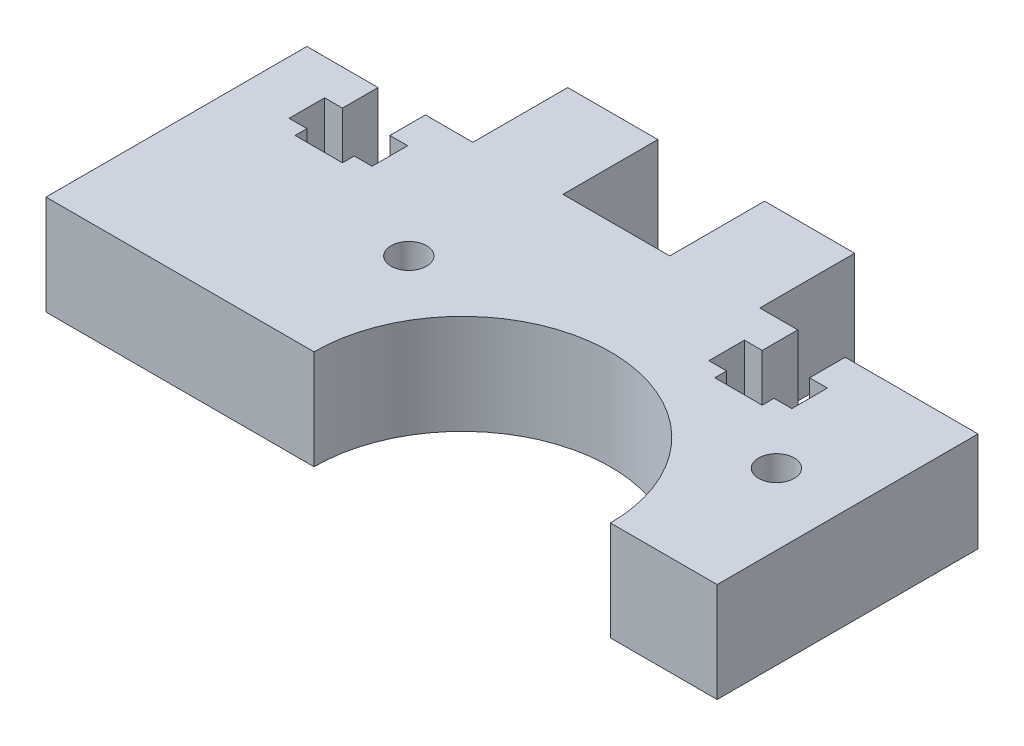
from build123d import *

# Parameters (mm, degrees)
SKETCH1_R           = 1.5
BOSS_EXTRUDE1_DEPTH = 8.4


with BuildPart() as part:
    # Sketch1 → Boss-Extrude1 (new body)
    with BuildSketch(Plane(origin=(0, 0, 0), x_dir=(1, 0, 0), z_dir=(0, 1, 0))):
        with BuildLine():
            Line((-28.3, 11), (-22.3, 11))
            Line((-22.3, 11), (-22.3, 8))
            Line((-22.3, 8), (-23.8, 8))
            Line((-23.8, 8), (-23.8, 5))
            Line((-23.8, 5), (-22.3, 5))
            Line((-22.3, 5), (-22.3, 4))
            Line((-22.3, 4), (-18.3, 4))
            Line((-18.3, 4), (-18.3, 5))
            Line((-18.3, 5), (-16.8, 5))
            Line((-16.8, 5), (-16.8, 8))
            Line((-16.8, 8), (-18.3, 8))
            Line((-18.3, 8), (-18.3, 11))
            Line((-18.3, 11), (-14.3, 11))
            Line((-14.3, 11), (-14.3, 19))
            Line((-14.3, 19), (-6.7, 19))
            Line((-6.7, 19), (-6.7, 11))
            Line((-6.7, 11), (2.3, 11))
            Line((2.3, 11), (2.3, 19))
            Line((2.3, 19), (9.9, 19))
            Line((9.9, 19), (9.9, 11))
            Line((9.9, 11), (13.1, 11))
            Line((13.1, 11), (13.1, 8))
            Line((13.1, 8), (11.6, 8))
            Line((11.6, 8), (11.6, 5))
            Line((11.6, 5), (13.1, 5))
            Line((13.1, 5), (13.1, 4))
            Line((13.1, 4), (17.1, 4))
            Line((17.1, 4), (17.1, 5))
            Line((17.1, 5), (18.6, 5))
            Line((18.6, 5), (18.6, 8))
            Line((18.6, 8), (17.1, 8))
            Line((17.1, 8), (17.1, 11))
            Line((17.1, 11), (28.3, 11))
            Line((28.3, 11), (28.3, -11))
            Line((28.3, -11), (19.3, -11))
            ThreePointArc((19.3, -11), (6.8, 1.5), (-5.7, -11))
            Line((-5.7, -11), (-28.3, -11))
            Line((-28.3, -11), (-28.3, 11))
        make_face()
        with Locations((-8.7, 0)):
            Circle(SKETCH1_R, mode=Mode.SUBTRACT)
        with Locations((22.3, 0)):
            Circle(SKETCH1_R, mode=Mode.SUBTRACT)
    extrude(amount=BOSS_EXTRUDE1_DEPTH)


solid = part.part
